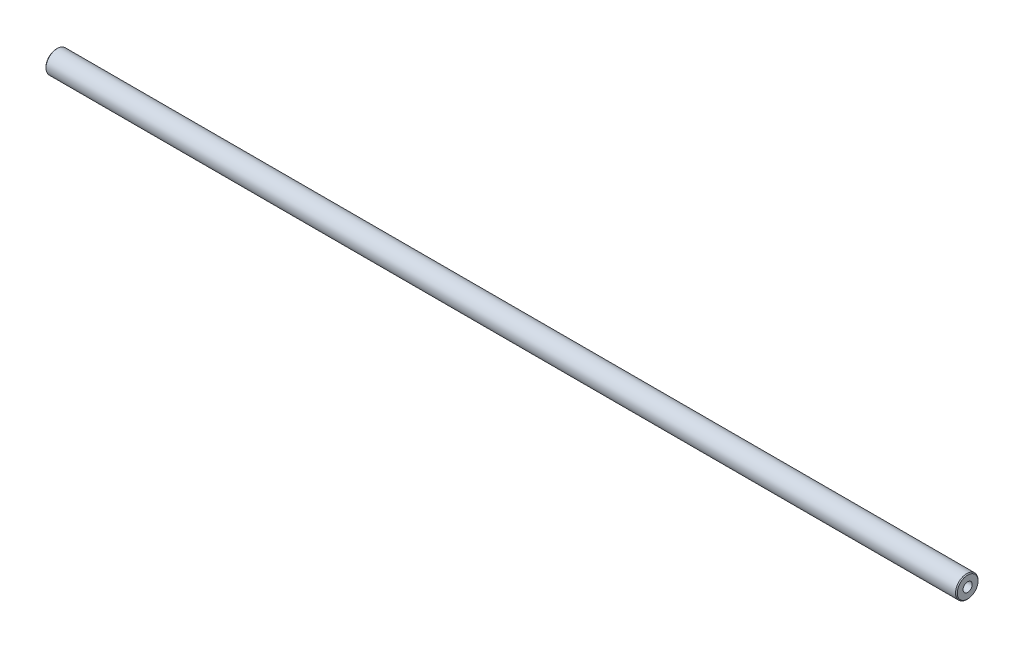
from build123d import *

# Parameters (mm, degrees)
CHAMFER1_SIZE = 0.5


with BuildPart() as part:
    # Sketch1 → Revolve1 (revolve)
    with BuildSketch(Plane(origin=(0, 0, 0), x_dir=(1, 0, 0), z_dir=(0, 1, 0))):
        Polygon((-257, 6.35), (257, 6.35), (257, 2.6), (235.2011107, 2.6), (233.7, 0), (-233.7, 0), (-235.2011107, 2.6), (-257, 2.6), align=None)
    revolve(axis=Axis((-267.305829972, 0, 0), (1, 0, 0)))

    # Chamfer1
    chamfer1_edges = [part.edges().sort_by_distance(p)[0] for p in [
        (257, 0, 6.35),
        (-257, 0, 6.35),
    ]]
    chamfer(chamfer1_edges, length=CHAMFER1_SIZE)


solid = part.part
